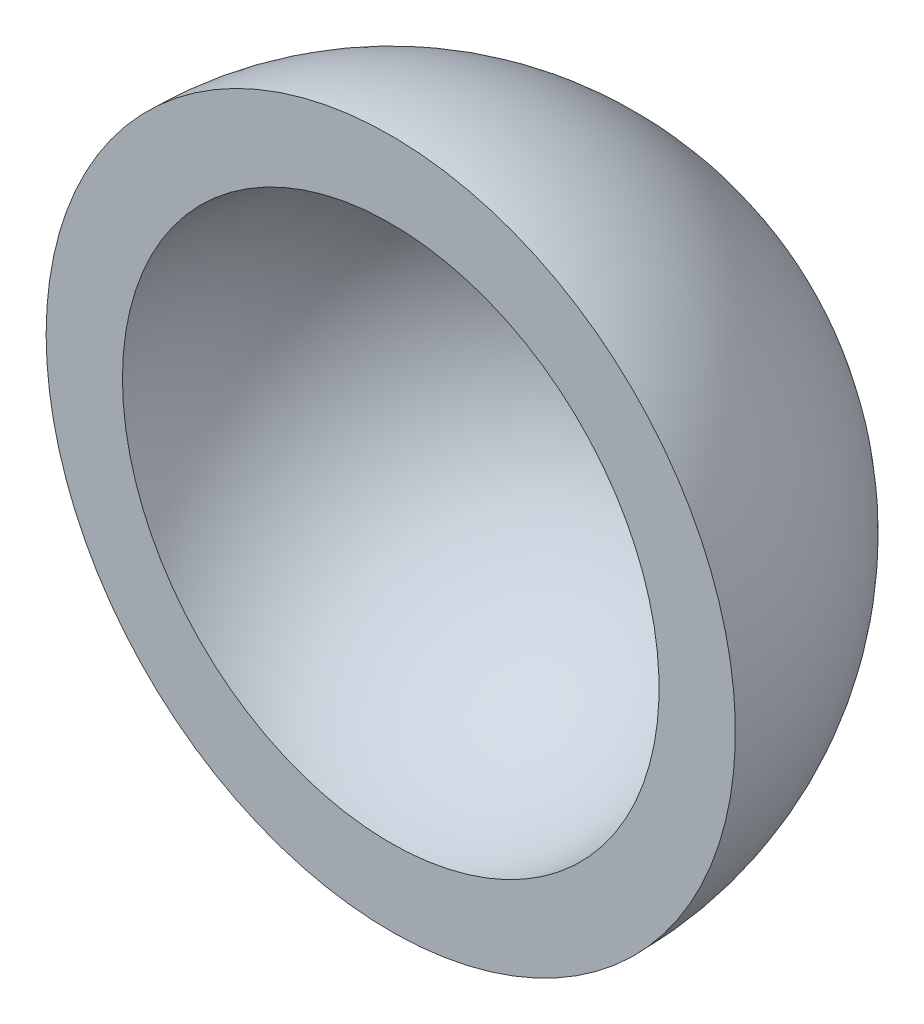
from build123d import *

# Parameters (mm, degrees)
REVOLVE5_ANGLE     = 180
CUT_REVOLVE1_ANGLE = 180


with BuildPart() as part:
    # Sketch1 → Revolve5 (revolve)
    with BuildSketch(Plane.XY):
        with BuildLine():
            Line((0, -62.5), (0, 62.5))
            ThreePointArc((0, 62.5), (62.5, 0), (0, -62.5))
        make_face()
    revolve(axis=Axis((0, -62.5, 0), (0, 1, 0)), revolution_arc=REVOLVE5_ANGLE)

    # Sketch2 → Cut-Revolve1 (revolve, cut)
    with BuildSketch(Plane.XY):
        with BuildLine():
            Line((0, -48.66), (0, 48.66))
            ThreePointArc((0, 48.66), (48.66, 0), (0, -48.66))
        make_face()
    revolve(axis=Axis((0, -48.66, 0), (0, 1, 0)), revolution_arc=CUT_REVOLVE1_ANGLE, mode=Mode.SUBTRACT)


solid = part.part
